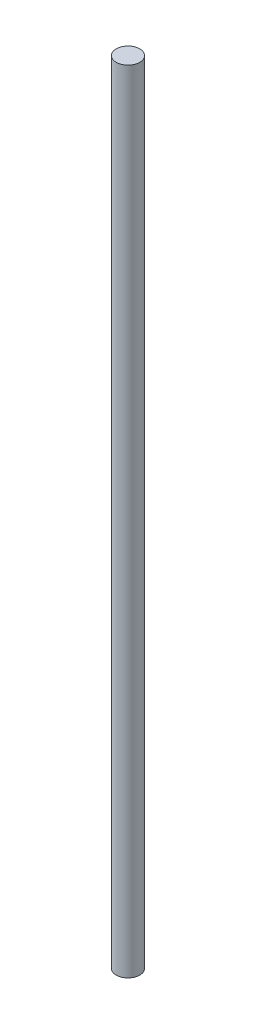
from build123d import *

# Parameters (mm, degrees)
SKETCH1_R           = 4
BOSS_EXTRUDE1_DEPTH = 270


with BuildPart() as part:
    # Sketch1 → Boss-Extrude1 (new body)
    with BuildSketch(Plane(origin=(0, 0, 0), x_dir=(1, 0, 0), z_dir=(0, 1, 0))):
        Circle(SKETCH1_R)
    extrude(amount=BOSS_EXTRUDE1_DEPTH)


solid = part.part
